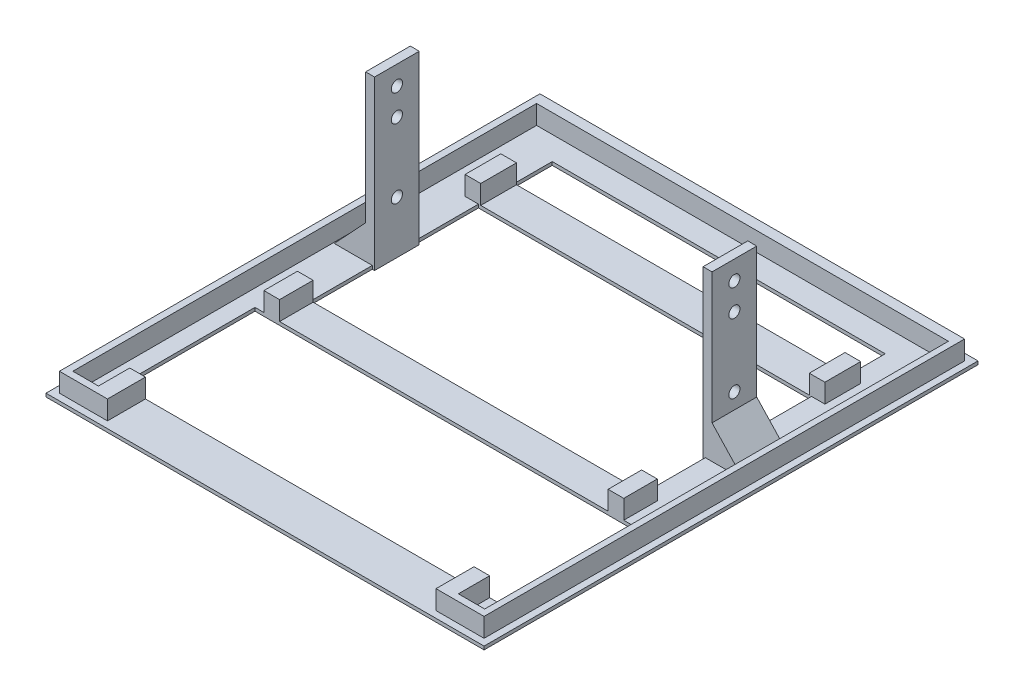
from build123d import *

# Parameters (mm, degrees)
SKETCH_1_W          = 196
SKETCH_1_H          = 221
SKETCH_1_W_2        = 169
SKETCH_1_H_2        = 60
SKETCH_1_W_3        = 149
SKETCH_1_H_3        = 75
SKETCH_1_H_4        = 17
SKETCH_1_W_4        = 159
SKETCH_1_H_5        = 3.5
EXTRUDE_1_DEPTH     = 1.5
SKETCH_5_W          = 7
SKETCH_5_H          = 16
SKETCH_5_H_2        = 15
EXTRUDE_9_DEPTH     = 10
CUT_EXTRUDE_2_DEPTH = 1.4
SKETCH_7_W          = 4
SKETCH_7_H          = 20
EXTRUDE_10_DEPTH    = 75
SKETCH_8_R          = 2.5
CUT_EXTRUDE_3_DEPTH = 185
EXTRUDE_11_DEPTH    = 20


with BuildPart() as part:
    # 草图1 → 凸台-拉伸1 (new body)
    with BuildSketch(Plane(origin=(0, 0, 0), x_dir=(1, 0, 0), z_dir=(0, 1, 0))):
        with Locations((98, 110.5)):
            Rectangle(SKETCH_1_W, SKETCH_1_H)
        with Locations((98, 50)):
            Rectangle(SKETCH_1_W_2, SKETCH_1_H_2, mode=Mode.SUBTRACT)
        with Locations((98, 132.5)):
            Rectangle(SKETCH_1_W_3, SKETCH_1_H_3, mode=Mode.SUBTRACT)
        with Locations((98, 194.5)):
            Rectangle(SKETCH_1_W_3, SKETCH_1_H_4, mode=Mode.SUBTRACT)
        with Locations((106.5, 216.25)):
            Rectangle(SKETCH_1_W_4, SKETCH_1_H_5, mode=Mode.SUBTRACT)
    extrude(amount=EXTRUDE_1_DEPTH)

    # 草图5 → 凸台-拉伸9 (add)
    with BuildSketch(Plane(origin=(0, 0, 0), x_dir=(1, 0, 0), z_dir=(0, 1, 0))):
        Polygon((3, 218), (193, 218), (193, 3), (171.5, 3), (171.5, 20), (178.5, 20), (178.5, 6), (190.27234206, 6), (190.27234206, 213.5), (6.00234206, 213.5), (6.00234206, 6), (17.473925125, 6), (17.473925125, 20), (24.5, 20), (24.5, 3), (3, 3), align=None)
        with Locations((21, 178)):
            Rectangle(SKETCH_5_W, SKETCH_5_H)
        with Locations((175, 178)):
            Rectangle(SKETCH_5_W, SKETCH_5_H)
        with Locations((175, 87.5)):
            Rectangle(SKETCH_5_W, SKETCH_5_H_2)
        with Locations((21, 87.5)):
            Rectangle(SKETCH_5_W, SKETCH_5_H_2)
    extrude(amount=EXTRUDE_9_DEPTH)

    # 草图6 → 切除-拉伸2 (cut)
    with BuildSketch(Plane(origin=(0, 0, 0), x_dir=(1, 0, 0), z_dir=(0, 1, 0))):
        Polygon((27, 217.586317154), (27, 218), (186, 218), (186, 215), (27, 215), align=None)
    extrude(amount=CUT_EXTRUDE_2_DEPTH, mode=Mode.SUBTRACT)

    # 草图7 → 凸台-拉伸10 (add)
    with BuildSketch(Plane(origin=(0, 0, 0), x_dir=(1, 0, 0), z_dir=(0, 1, 0))):
        Polygon((175.5, 132.5), (175.5, 142.5), (171.5, 142.5), (171.5, 122.5), (175.5, 122.5), align=None)
        with Locations((22.5, 132.5)):
            Rectangle(SKETCH_7_W, SKETCH_7_H)
    extrude(amount=EXTRUDE_10_DEPTH)

    # 草图8 → 切除-拉伸3 (cut)
    with BuildSketch(Plane(origin=(175.5, 0, 0), x_dir=(0, 0, -1), z_dir=(1, 0, 0))):
        with Locations((132.5, 66.5)):
            Circle(SKETCH_8_R)
        with Locations((132.5, 54.5)):
            Circle(SKETCH_8_R)
        with Locations((132.5, 23.5)):
            Circle(SKETCH_8_R)
    extrude(amount=-CUT_EXTRUDE_3_DEPTH, mode=Mode.SUBTRACT)

    # 草图10 → 凸台-拉伸11 (add)
    with BuildSketch(Plane(origin=(0, 0, -142.5), x_dir=(-1, 0, 0), z_dir=(0, 0, -1))):
        Polygon((-189.5, 1.5), (-175.5, 1.5), (-175.5, 16.5), align=None)
        Polygon((-20.5, 1.5), (-6.5, 1.5), (-20.5, 16.5), align=None)
    extrude(amount=-EXTRUDE_11_DEPTH)


solid = part.part
